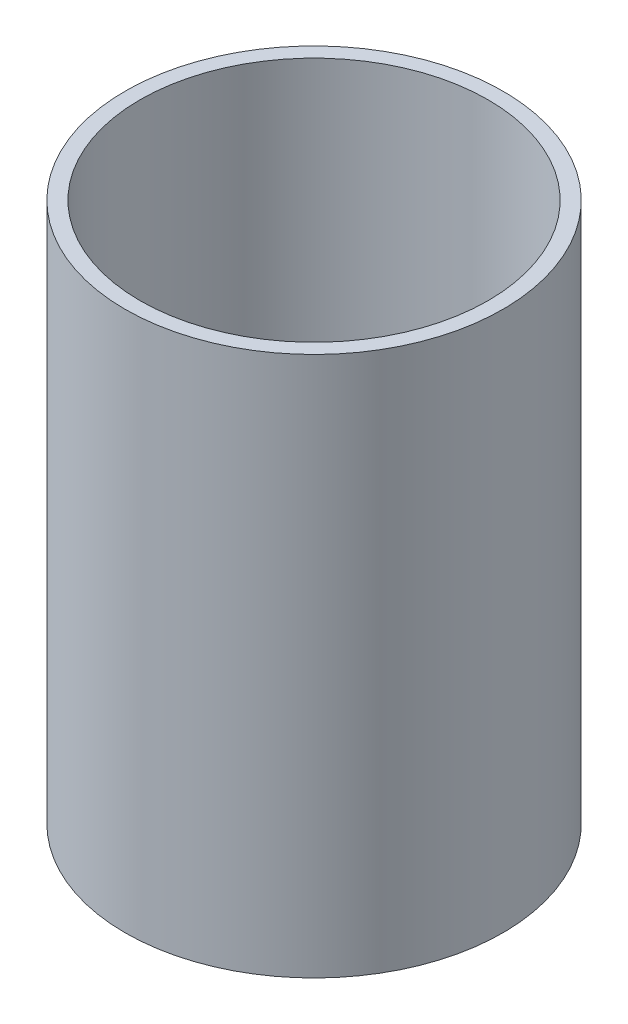
from build123d import *

# Parameters (mm, degrees)
SKETCH1_R                = 19
SKETCH1_R_2              = 17.5
BOSS_EXTRUDE1_DEPTH      = 52.3
RESSALTO_EXTRUS_O1_START = -2
SKETCH1_2_R              = 19
RESSALTO_EXTRUS_O1_DEPTH = 2


with BuildPart() as part:
    # Sketch1 → Boss-Extrude1 (new body)
    with BuildSketch(Plane(origin=(0, 0, 0), x_dir=(1, 0, 0), z_dir=(0, 1, 0))):
        Circle(SKETCH1_R)
        Circle(SKETCH1_R_2, mode=Mode.SUBTRACT)
    extrude(amount=BOSS_EXTRUDE1_DEPTH)

    # Sketch1_2 → Ressalto-extrus_o1 (add)
    with BuildSketch(Plane(origin=(0, 0, 0), x_dir=(1, 0, 0), z_dir=(0, 1, 0)).offset(RESSALTO_EXTRUS_O1_START)):
        Circle(SKETCH1_2_R)
    extrude(amount=RESSALTO_EXTRUS_O1_DEPTH)


solid = part.part
